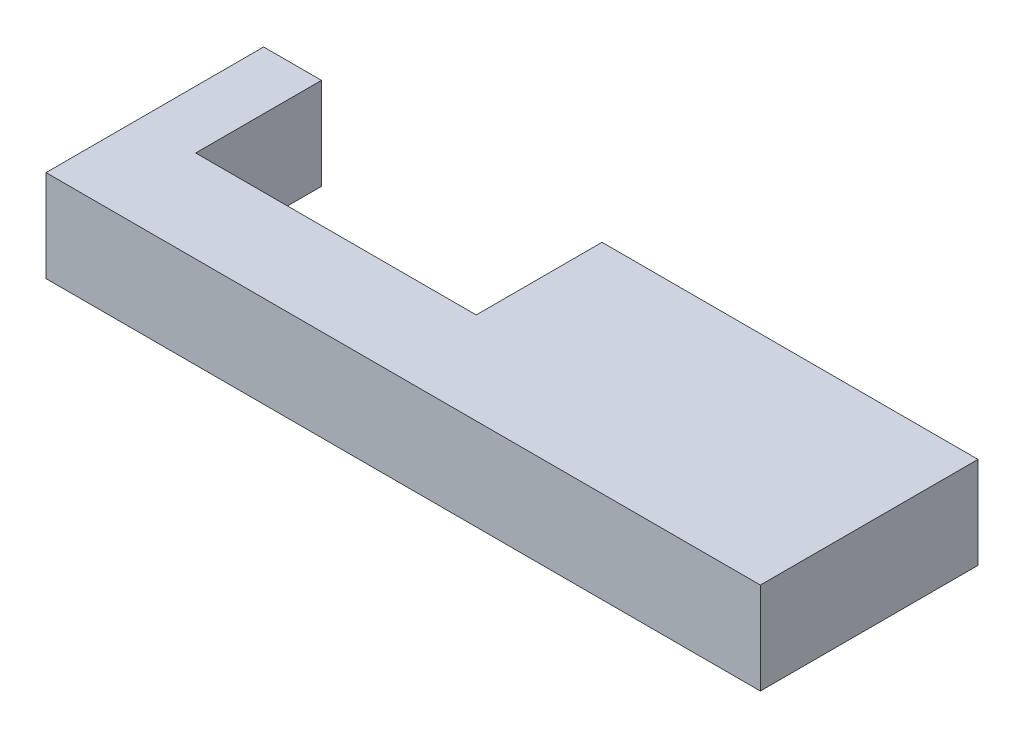
from build123d import *

# Parameters (mm, degrees)
BOSS_EXTRUDE1_DEPTH = 6.35
SKETCH3_W           = 15.05
SKETCH3_H           = 6.35
BOSS_EXTRUDE2_DEPTH = 22


with BuildPart() as part:
    # Sketch1 → Boss-Extrude1 (new body)
    with BuildSketch(Plane(origin=(0, 0, 0), x_dir=(1, 0, 0), z_dir=(0, 1, 0))):
        Polygon((0, 0), (19.4, 0), (19.4, 8.7), (23.4, 8.7), (23.4, -6.35), (-4, -6.35), (-4, 8.7), (0, 8.7), align=None)
    extrude(amount=BOSS_EXTRUDE1_DEPTH)

    # Sketch3 → Boss-Extrude2 (add)
    with BuildSketch(Plane(origin=(23.4, 0, 0), x_dir=(0, 0, -1), z_dir=(1, 0, 0))):
        with Locations((1.175, 3.175)):
            Rectangle(SKETCH3_W, SKETCH3_H)
    extrude(amount=BOSS_EXTRUDE2_DEPTH)


solid = part.part
